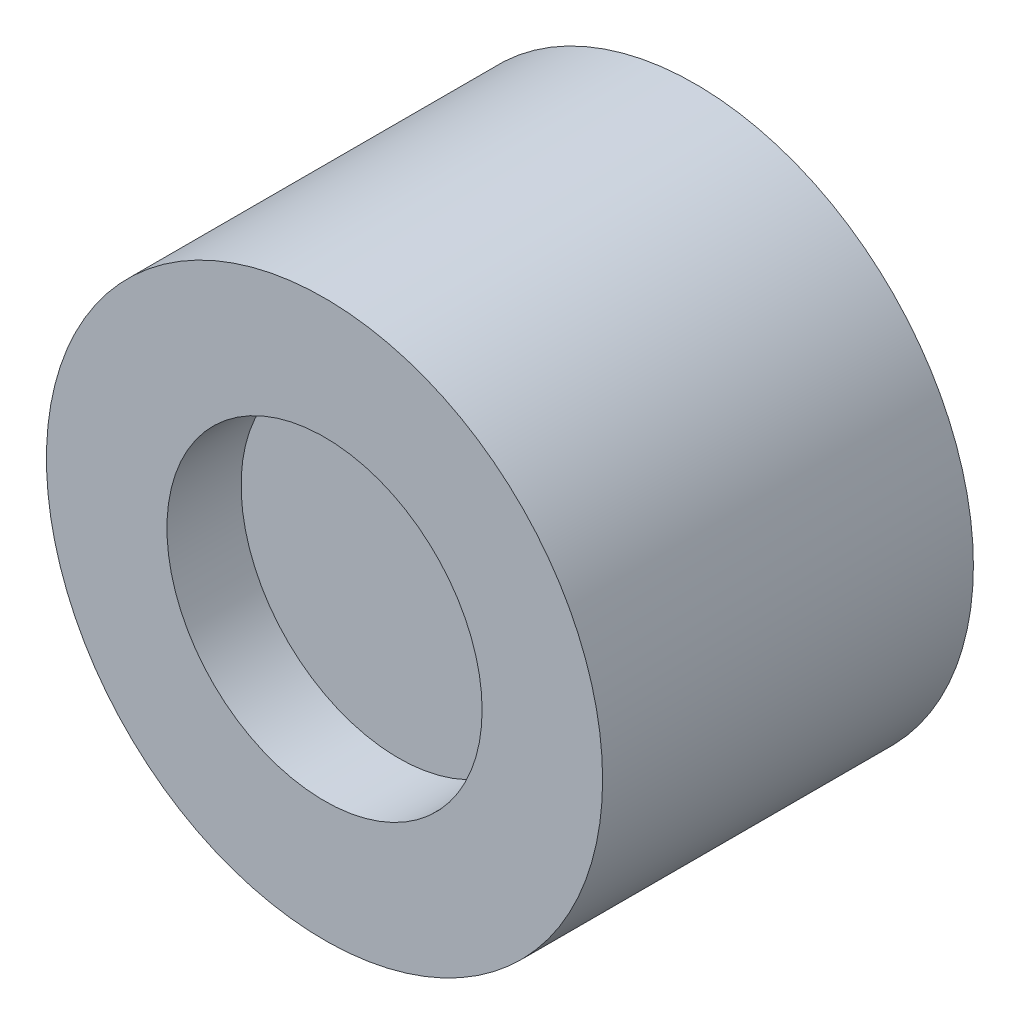
from build123d import *

# Parameters (mm, degrees)
CROQUIS1_R              = 7.5
SALIENTE_EXTRUIR1_DEPTH = 10
CROQUIS2_R              = 4.25
CORTAR_EXTRUIR1_DEPTH   = 2


with BuildPart() as part:
    # Croquis1 → Saliente-Extruir1 (new body)
    with BuildSketch(Plane.XY):
        Circle(CROQUIS1_R)
    extrude(amount=SALIENTE_EXTRUIR1_DEPTH)

    # Croquis2 → Cortar-Extruir1 (cut)
    with BuildSketch(Plane.XY.offset(10)):
        Circle(CROQUIS2_R)
    extrude(amount=-CORTAR_EXTRUIR1_DEPTH, mode=Mode.SUBTRACT)


solid = part.part
